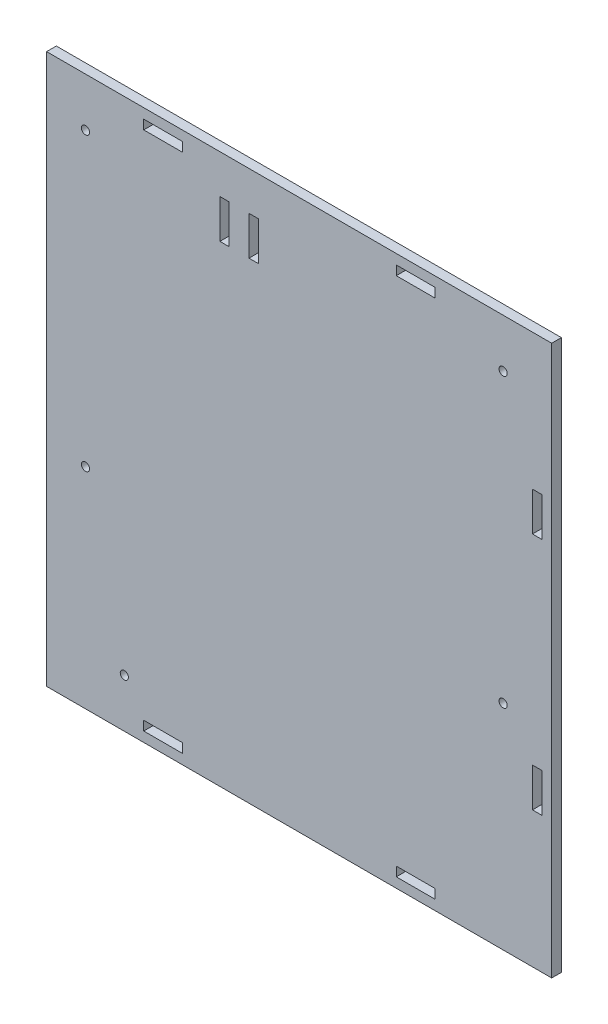
from build123d import *

# Parameters (mm, degrees)
SKETCH1_W           = 260
SKETCH1_H           = 283
SKETCH1_W_2         = 20
SKETCH1_H_2         = 4.8
SKETCH1_W_3         = 4.8
SKETCH1_H_3         = 20
BOSS_EXTRUDE1_DEPTH = 5
SKETCH2_W           = 4.8
SKETCH2_H           = 20
CUT_EXTRUDE1_DEPTH  = 5
SKETCH3_R           = 2.1
CUT_EXTRUDE2_DEPTH  = 5
SKETCH4_R           = 2.1
CUT_EXTRUDE3_DEPTH  = 5
SKETCH5_R           = 2.1
CUT_EXTRUDE4_DEPTH  = 5
SKETCH6_R           = 2.1
CUT_EXTRUDE5_DEPTH  = 5


with BuildPart() as part:
    # Sketch1 → Boss-Extrude1 (new body)
    with BuildSketch(Plane.XY):
        with Locations((-120, 136.5)):
            Rectangle(SKETCH1_W, SKETCH1_H)
        with Locations((-190, 2.5)):
            Rectangle(SKETCH1_W_2, SKETCH1_H_2, mode=Mode.SUBTRACT)
        with Locations((-60, 2.5)):
            Rectangle(SKETCH1_W_2, SKETCH1_H_2, mode=Mode.SUBTRACT)
        with Locations((2.5, 75)):
            Rectangle(SKETCH1_W_3, SKETCH1_H_3, mode=Mode.SUBTRACT)
        with Locations((2.5, 198)):
            Rectangle(SKETCH1_W_3, SKETCH1_H_3, mode=Mode.SUBTRACT)
        with Locations((-60, 270.5)):
            Rectangle(SKETCH1_W_2, SKETCH1_H_2, mode=Mode.SUBTRACT)
        with Locations((-190, 270.5)):
            Rectangle(SKETCH1_W_2, SKETCH1_H_2, mode=Mode.SUBTRACT)
    extrude(amount=BOSS_EXTRUDE1_DEPTH)

    # Sketch2 → Cut-Extrude1 (cut)
    with BuildSketch(Plane.XY.offset(5)):
        with Locations((-143.405234687, 248)):
            Rectangle(SKETCH2_W, SKETCH2_H)
        with Locations((-158.405234687, 248)):
            Rectangle(SKETCH2_W, SKETCH2_H)
    extrude(amount=-CUT_EXTRUDE1_DEPTH, mode=Mode.SUBTRACT)

    # Sketch3 → Cut-Extrude2 (cut)
    with BuildSketch(Plane.XY.offset(5)):
        with Locations((-230, 253)):
            Circle(SKETCH3_R)
        with Locations((-15, 253)):
            Circle(SKETCH3_R)
    extrude(amount=-CUT_EXTRUDE2_DEPTH, mode=Mode.SUBTRACT)

    # Sketch4 → Cut-Extrude3 (cut)
    with BuildSketch(Plane.XY.offset(5)):
        with Locations((-210, 20)):
            Circle(SKETCH4_R)
    extrude(amount=-CUT_EXTRUDE3_DEPTH, mode=Mode.SUBTRACT)

    # Sketch5 → Cut-Extrude4 (cut)
    with BuildSketch(Plane.XY.offset(5)):
        with Locations((-15, 105)):
            Circle(SKETCH5_R)
    extrude(amount=-CUT_EXTRUDE4_DEPTH, mode=Mode.SUBTRACT)

    # Sketch6 → Cut-Extrude5 (cut)
    with BuildSketch(Plane.XY.offset(5)):
        with Locations((-230, 103)):
            Circle(SKETCH6_R)
    extrude(amount=-CUT_EXTRUDE5_DEPTH, mode=Mode.SUBTRACT)


solid = part.part
